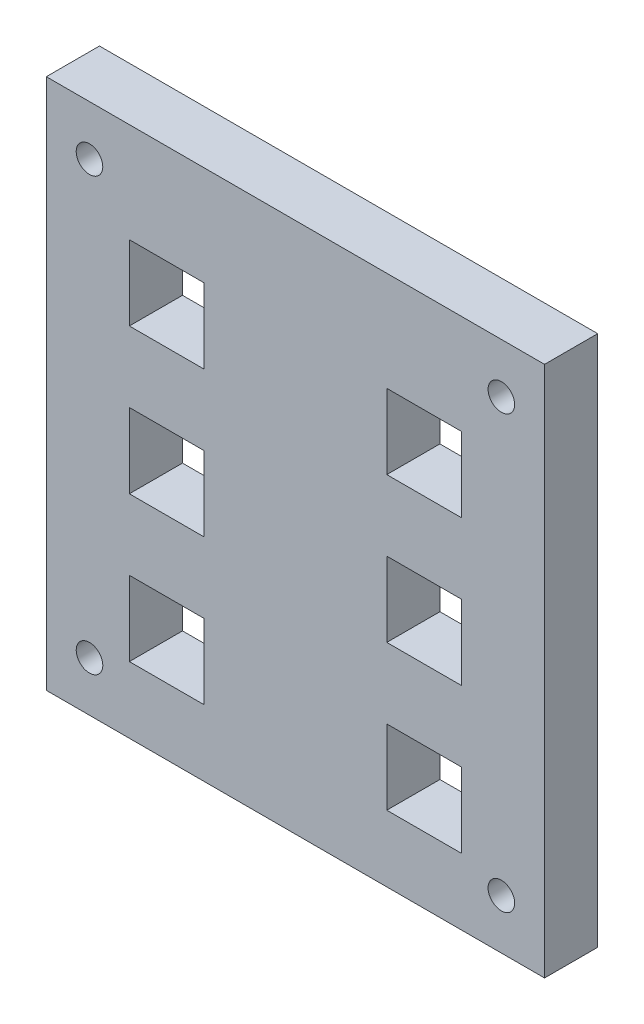
from build123d import *

# Parameters (mm, degrees)
SKETCH1_W           = 150
SKETCH1_H           = 160
BOSS_EXTRUDE1_DEPTH = 16
SKETCH4_R           = 4
SKETCH4_W           = 22.5
SKETCH4_H           = 22.5
CUT_EXTRUDE1_DEPTH  = 17


with BuildPart() as part:
    # Sketch1 → Boss-Extrude1 (new body)
    with BuildSketch(Plane.XY):
        Rectangle(SKETCH1_W, SKETCH1_H)
    extrude(amount=BOSS_EXTRUDE1_DEPTH)

    # Sketch4 → Cut-Extrude1 (cut, through all)
    with BuildSketch(Plane.XY.offset(16)):
        with Locations((-62, 65)):
            Circle(SKETCH4_R)
        with Locations((62, 65)):
            Circle(SKETCH4_R)
        with Locations((62, -65)):
            Circle(SKETCH4_R)
        with Locations((-62, -65)):
            Circle(SKETCH4_R)
        with Locations((-38.75, 38.75)):
            Rectangle(SKETCH4_W, SKETCH4_H)
        with Locations((38.75, 38.75)):
            Rectangle(SKETCH4_W, SKETCH4_H)
        with Locations((-38.75, -48.75)):
            Rectangle(SKETCH4_W, SKETCH4_H)
        with Locations((38.75, -48.75)):
            Rectangle(SKETCH4_W, SKETCH4_H)
        with Locations((-38.75, -5)):
            Rectangle(SKETCH4_W, SKETCH4_H)
        with Locations((38.75, -5)):
            Rectangle(SKETCH4_W, SKETCH4_H)
    extrude(amount=-CUT_EXTRUDE1_DEPTH, mode=Mode.SUBTRACT)


solid = part.part
